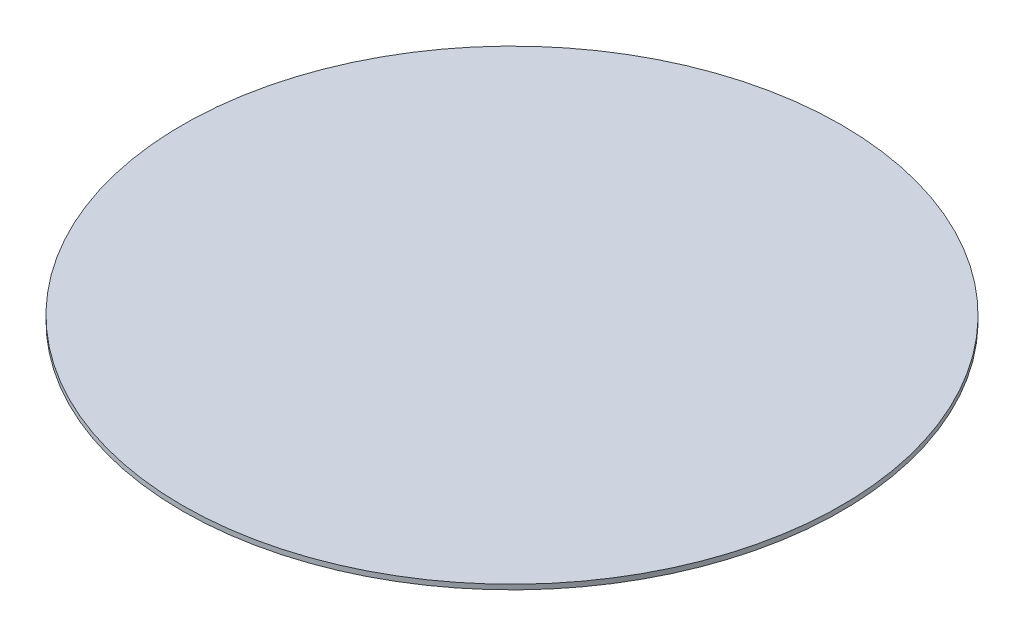
from build123d import *

# Parameters (mm, degrees)
SKETCH1_R           = 67.5
BOSS_EXTRUDE1_DEPTH = 1


with BuildPart() as part:
    # Sketch1 → Boss-Extrude1 (new body)
    with BuildSketch(Plane(origin=(0, 0, 0), x_dir=(1, 0, 0), z_dir=(0, 1, 0))):
        Circle(SKETCH1_R)
    extrude(amount=BOSS_EXTRUDE1_DEPTH)


solid = part.part
